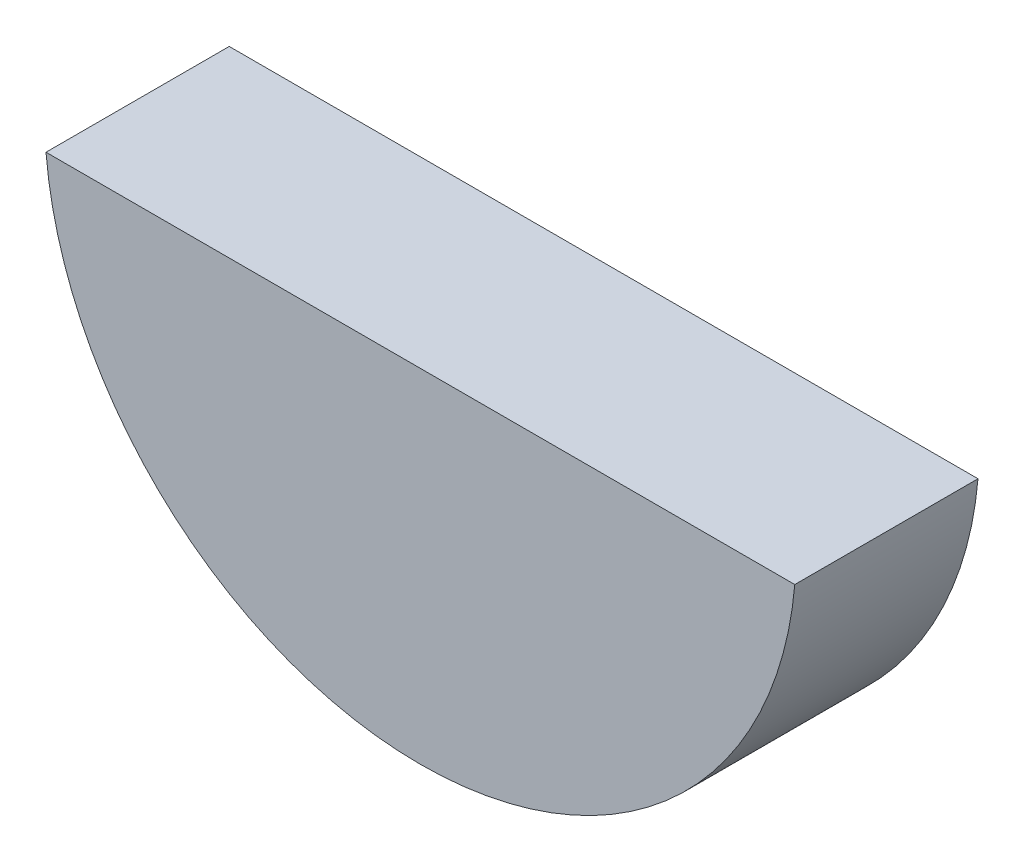
from build123d import *

# Parameters (mm, degrees)
ESTRUSIONE_ESTRUSIONE1_DEPTH = 3.9
SCHIZZO2_W                   = 16
SCHIZZO2_H                   = 3.9
TAGLIO_ESTRUSIONE1_DEPTH     = 0.7


with BuildPart() as part:
    # Schizzo1 → Estrusione-Estrusione1 (new body)
    with BuildSketch(Plane.XY):
        with BuildLine():
            Line((-8, 0), (8, 0))
            ThreePointArc((8, 0), (0, -8), (-8, 0))
        make_face()
    extrude(amount=ESTRUSIONE_ESTRUSIONE1_DEPTH)

    # Schizzo2 → Taglio-Estrusione1 (cut)
    with BuildSketch(Plane(origin=(0, 0, 0), x_dir=(1, 0, 0), z_dir=(0, 1, 0))):
        with Locations((0, -1.95)):
            Rectangle(SCHIZZO2_W, SCHIZZO2_H)
    extrude(amount=-TAGLIO_ESTRUSIONE1_DEPTH, mode=Mode.SUBTRACT)


solid = part.part
